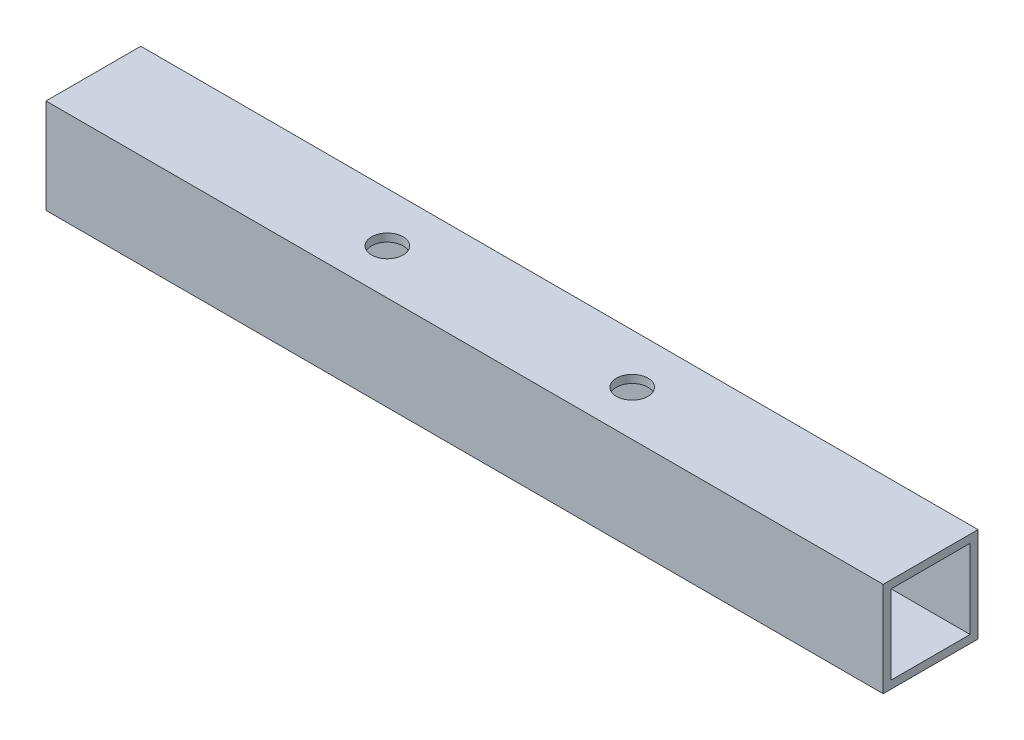
from build123d import *

# Parameters (mm, degrees)
SKETCH1_W           = 106
SKETCH1_H           = 12
BOSS_EXTRUDE1_DEPTH = 12
SKETCH2_R           = 2
CUT_EXTRUDE1_DEPTH  = 12
SKETCH3_W           = 10
SKETCH3_H           = 10
CUT_EXTRUDE2_DEPTH  = 128


with BuildPart() as part:
    # Sketch1 → Boss-Extrude1 (new body)
    with BuildSketch(Plane.XY):
        Rectangle(SKETCH1_W, SKETCH1_H)
    extrude(amount=BOSS_EXTRUDE1_DEPTH)

    # Sketch2 → Cut-Extrude1 (cut)
    with BuildSketch(Plane(origin=(0, 6, 0), x_dir=(1, 0, 0), z_dir=(0, 1, 0))):
        with Locations((-15.5, -6.282258571)):
            Circle(SKETCH2_R)
        with Locations((15.5, -6.282258571)):
            Circle(SKETCH2_R)
    extrude(amount=-CUT_EXTRUDE1_DEPTH, mode=Mode.SUBTRACT)

    # Sketch3 → Cut-Extrude2 (cut)
    with BuildSketch(Plane(origin=(53, 0, 0), x_dir=(0, 0, -1), z_dir=(1, 0, 0))):
        with Locations((-6, 0)):
            Rectangle(SKETCH3_W, SKETCH3_H)
    extrude(amount=-CUT_EXTRUDE2_DEPTH, mode=Mode.SUBTRACT)


solid = part.part
